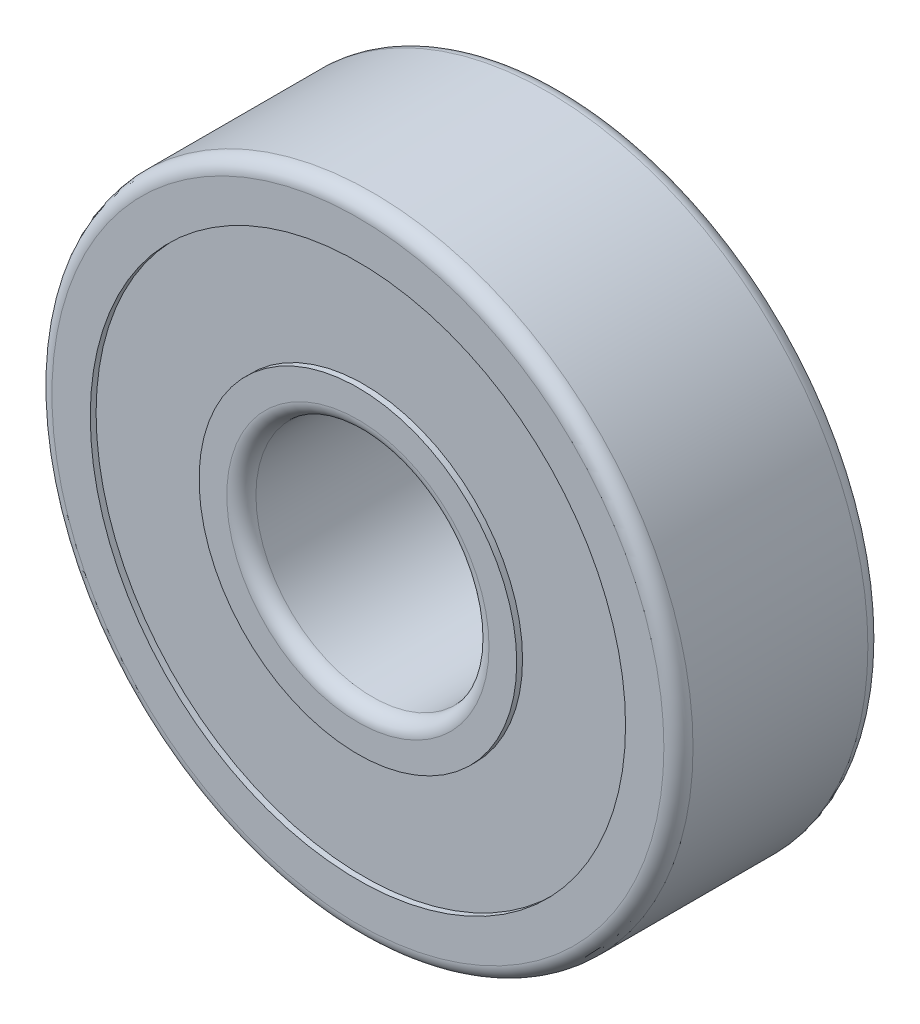
from build123d import *

# Parameters (mm, degrees)
SZKIC1_R                    = 11
SZKIC1_R_2                  = 4
DODANIE_WYCI_GNI_CIE1_DEPTH = 3.5
SZKIC2_R                    = 9.184724544
SZKIC2_R_2                  = 5.450254851
WYTNIJ_WYCI_GNI_CIE1_DEPTH  = 0.2
ZAOKR_GLENIE1_R             = 0.5


with BuildPart() as part:
    # Szkic1 → Dodanie-wyciągnięcie1 (new body, symmetric)
    with BuildSketch(Plane.XY):
        Circle(SZKIC1_R)
        Circle(SZKIC1_R_2, mode=Mode.SUBTRACT)
    extrude(amount=DODANIE_WYCI_GNI_CIE1_DEPTH, both=True)

    # Szkic2 → Wytnij-wyciągnięcie1 (cut)
    with BuildSketch(Plane.XY.offset(3.5)):
        Circle(SZKIC2_R)
        Circle(SZKIC2_R_2, mode=Mode.SUBTRACT)
    wytnij_wyci_gni_cie1 = extrude(amount=-WYTNIJ_WYCI_GNI_CIE1_DEPTH, mode=Mode.SUBTRACT)

    # Lustro1: Wytnij-wyciągnięcie1 across plane
    add(wytnij_wyci_gni_cie1.mirror(Plane.XY), mode=Mode.SUBTRACT)

    # Zaokrąglenie1
    zaokr_glenie1_edges = [part.edges().sort_by_distance(p)[0] for p in [
        (-11, 0, -3.5),
        (-11, 0, 3.5),
        (-4, 0, -3.5),
        (-4, 0, 3.5),
    ]]
    fillet(zaokr_glenie1_edges, radius=ZAOKR_GLENIE1_R)


solid = part.part
